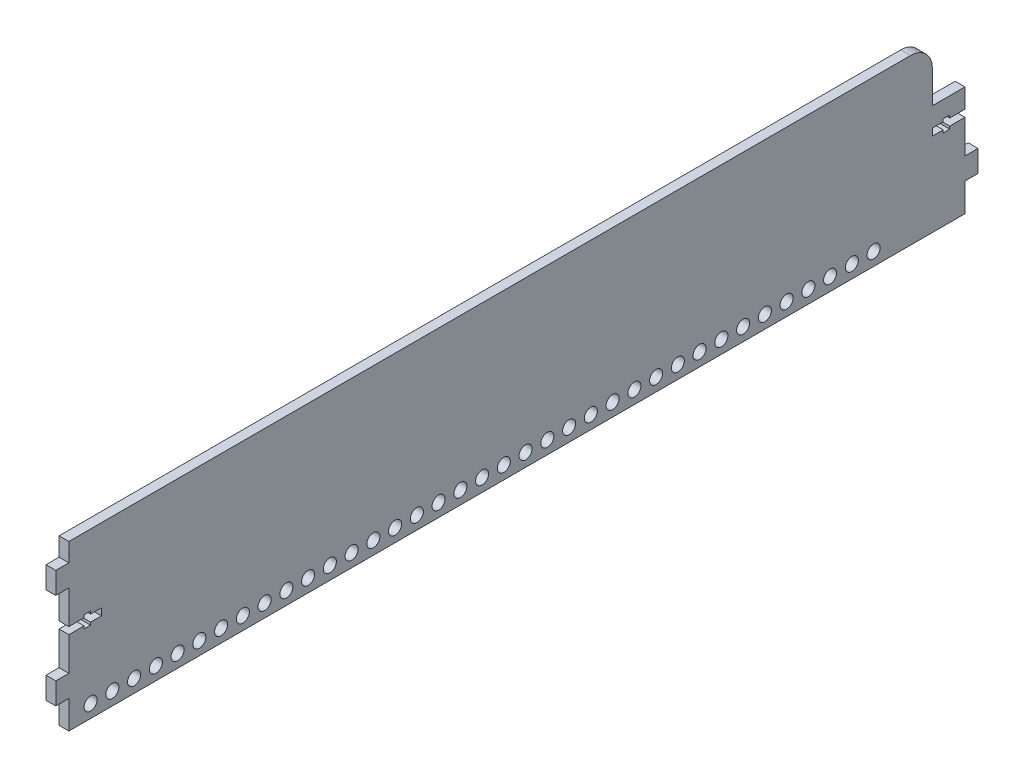
from build123d import *

# Parameters (mm, degrees)
SKETCH1_W           = 412
SKETCH1_H           = 80
BOSS_EXTRUDE1_DEPTH = 4.5
SKETCH4_W           = 4.5
SKETCH4_H           = 10
BOSS_EXTRUDE2_DEPTH = 6
CUT_EXTRUDE3_REACH  = 6.5
SKETCH7_W           = 4.5
SKETCH7_H           = 10
BOSS_EXTRUDE3_DEPTH = 6
SKETCH8_W           = 4.5
SKETCH8_H           = 412
CUT_EXTRUDE4_DEPTH  = 4.5
SKETCH9_W           = 4.5
SKETCH9_H           = 15
CUT_EXTRUDE5_DEPTH  = 25
FILLET1_R           = 10
SKETCH10_R          = 3
CUT_EXTRUDE6_DEPTH  = 4.5


with BuildPart() as part:
    # Sketch1 → Boss-Extrude1 (new body)
    with BuildSketch(Plane(origin=(0, 0, 0), x_dir=(0, 0, -1), z_dir=(1, 0, 0))):
        Rectangle(SKETCH1_W, SKETCH1_H)
    extrude(amount=BOSS_EXTRUDE1_DEPTH)

    # Sketch4 → Boss-Extrude2 (add)
    with BuildSketch(Plane.XY.offset(206)):
        with Locations((2.25, 22)):
            Rectangle(SKETCH4_W, SKETCH4_H)
        with Locations((2.25, -22)):
            Rectangle(SKETCH4_W, SKETCH4_H)
    extrude(amount=BOSS_EXTRUDE2_DEPTH)

    # Sketch5 → Cut-Extrude3 (cut, up to next)
    with BuildSketch(Plane.ZY, mode=Mode.PRIVATE) as cut_extrude3_sk1:
        Polygon((206, -1.6), (206, 1.6), (199, 1.6), (199, 2.8), (196, 2.8), (196, 1.6), (191, 1.6), (191, -1.6), (196, -1.6), (196, -2.8), (199, -2.8), (199, -1.6), align=None)
    cut_extrude3_tool1 = extrude(cut_extrude3_sk1.sketch, amount=-CUT_EXTRUDE3_REACH, mode=Mode.PRIVATE) & part.part
    add(cut_extrude3_tool1.solids().sort_by_distance((0, 0, 198.369565))[0], mode=Mode.SUBTRACT)
    # Sketch5 → Cut-Extrude3 (cut, up to next)
    with BuildSketch(Plane.ZY, mode=Mode.PRIVATE) as cut_extrude3_sk2:
        Polygon((-206, -1.6), (-206, 1.6), (-199, 1.6), (-199, 2.8), (-196, 2.8), (-196, 1.6), (-191, 1.6), (-191, -1.6), (-196, -1.6), (-196, -2.8), (-199, -2.8), (-199, -1.6), align=None)
    cut_extrude3_tool2 = extrude(cut_extrude3_sk2.sketch, amount=-CUT_EXTRUDE3_REACH, mode=Mode.PRIVATE) & part.part
    add(cut_extrude3_tool2.solids().sort_by_distance((0, 0, -198.369565))[0], mode=Mode.SUBTRACT)

    # Sketch7 → Boss-Extrude3 (add)
    with BuildSketch(Plane(origin=(0, 0, -206), x_dir=(-1, 0, 0), z_dir=(0, 0, -1))):
        with Locations((-2.25, -22)):
            Rectangle(SKETCH7_W, SKETCH7_H)
    extrude(amount=BOSS_EXTRUDE3_DEPTH)

    # Sketch8 → Cut-Extrude4 (cut)
    with BuildSketch(Plane(origin=(0, 40, 0), x_dir=(1, 0, 0), z_dir=(0, 1, 0))):
        with Locations((2.25, 0)):
            Rectangle(SKETCH8_W, SKETCH8_H)
    extrude(amount=-CUT_EXTRUDE4_DEPTH, mode=Mode.SUBTRACT)

    # Sketch9 → Cut-Extrude5 (cut)
    with BuildSketch(Plane(origin=(0, 35.5, 0), x_dir=(1, 0, 0), z_dir=(0, 1, 0))):
        with Locations((2.25, 198.5)):
            Rectangle(SKETCH9_W, SKETCH9_H)
    extrude(amount=-CUT_EXTRUDE5_DEPTH, mode=Mode.SUBTRACT)

    # Fillet1
    fillet1_edges = [part.edges().sort_by_distance(p)[0] for p in [
        (2.25, 35.5, -191),
    ]]
    fillet(fillet1_edges, radius=FILLET1_R)

    # Sketch10 → Cut-Extrude6 (cut)
    with BuildSketch(Plane.ZY):
        with Locations((196, -34)):
            Circle(SKETCH10_R)
        with Locations((186, -34)):
            Circle(SKETCH10_R)
        with Locations((176, -34)):
            Circle(SKETCH10_R)
        with Locations((166, -34)):
            Circle(SKETCH10_R)
        with Locations((156, -34)):
            Circle(SKETCH10_R)
        with Locations((146, -34)):
            Circle(SKETCH10_R)
        with Locations((136, -34)):
            Circle(SKETCH10_R)
        with Locations((126, -34)):
            Circle(SKETCH10_R)
        with Locations((116, -34)):
            Circle(SKETCH10_R)
        with Locations((106, -34)):
            Circle(SKETCH10_R)
        with Locations((96, -34)):
            Circle(SKETCH10_R)
        with Locations((86, -34)):
            Circle(SKETCH10_R)
        with Locations((76, -34)):
            Circle(SKETCH10_R)
        with Locations((66, -34)):
            Circle(SKETCH10_R)
        with Locations((56, -34)):
            Circle(SKETCH10_R)
        with Locations((46, -34)):
            Circle(SKETCH10_R)
        with Locations((36, -34)):
            Circle(SKETCH10_R)
        with Locations((26, -34)):
            Circle(SKETCH10_R)
        with Locations((16, -34)):
            Circle(SKETCH10_R)
        with Locations((6, -34)):
            Circle(SKETCH10_R)
        with Locations((-4, -34)):
            Circle(SKETCH10_R)
        with Locations((-14, -34)):
            Circle(SKETCH10_R)
        with Locations((-24, -34)):
            Circle(SKETCH10_R)
        with Locations((-34, -34)):
            Circle(SKETCH10_R)
        with Locations((-44, -34)):
            Circle(SKETCH10_R)
        with Locations((-54, -34)):
            Circle(SKETCH10_R)
        with Locations((-64, -34)):
            Circle(SKETCH10_R)
        with Locations((-74, -34)):
            Circle(SKETCH10_R)
        with Locations((-84, -34)):
            Circle(SKETCH10_R)
        with Locations((-94, -34)):
            Circle(SKETCH10_R)
        with Locations((-104, -34)):
            Circle(SKETCH10_R)
        with Locations((-114, -34)):
            Circle(SKETCH10_R)
        with Locations((-124, -34)):
            Circle(SKETCH10_R)
        with Locations((-134, -34)):
            Circle(SKETCH10_R)
        with Locations((-144, -34)):
            Circle(SKETCH10_R)
        with Locations((-154, -34)):
            Circle(SKETCH10_R)
        with Locations((-164, -34)):
            Circle(SKETCH10_R)
    extrude(amount=-CUT_EXTRUDE6_DEPTH, mode=Mode.SUBTRACT)


solid = part.part
